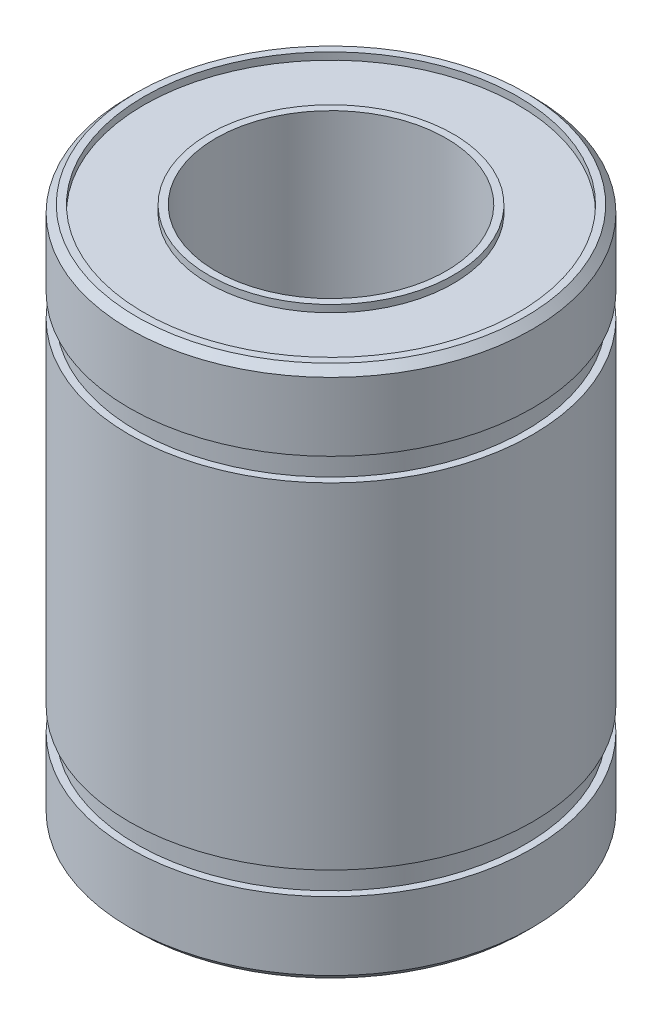
from build123d import *

# Parameters (mm, degrees)
SKETCH2_R          = 13
SKETCH2_R_2        = 8.5
CUT_EXTRUDE1_DEPTH = 0.5


with BuildPart() as part:
    # Sketch1 → Revolve1 (revolve)
    with BuildSketch(Plane.XY):
        Polygon((8, -18.5), (8, 18.5), (13.5, 18.5), (14, 18), (14, 13.25), (13.5, 13.25), (13.5, 11.65), (14, 11.65), (14, -11.65), (13.5, -11.65), (13.5, -13.25), (14, -13.25), (14, -18), (13.5, -18.5), align=None)
    revolve(axis=Axis((0, 18.5, 0), (0, -1, 0)))

    # Sketch2 → Cut-Extrude1 (cut)
    with BuildSketch(Plane(origin=(0, 18.5, 0), x_dir=(1, 0, 0), z_dir=(0, 1, 0))):
        Circle(SKETCH2_R)
        Circle(SKETCH2_R_2, mode=Mode.SUBTRACT)
    cut_extrude1 = extrude(amount=-CUT_EXTRUDE1_DEPTH, mode=Mode.SUBTRACT)

    # Mirror1: Cut-Extrude1 across plane
    add(cut_extrude1.mirror(Plane.ZX), mode=Mode.SUBTRACT)


solid = part.part
